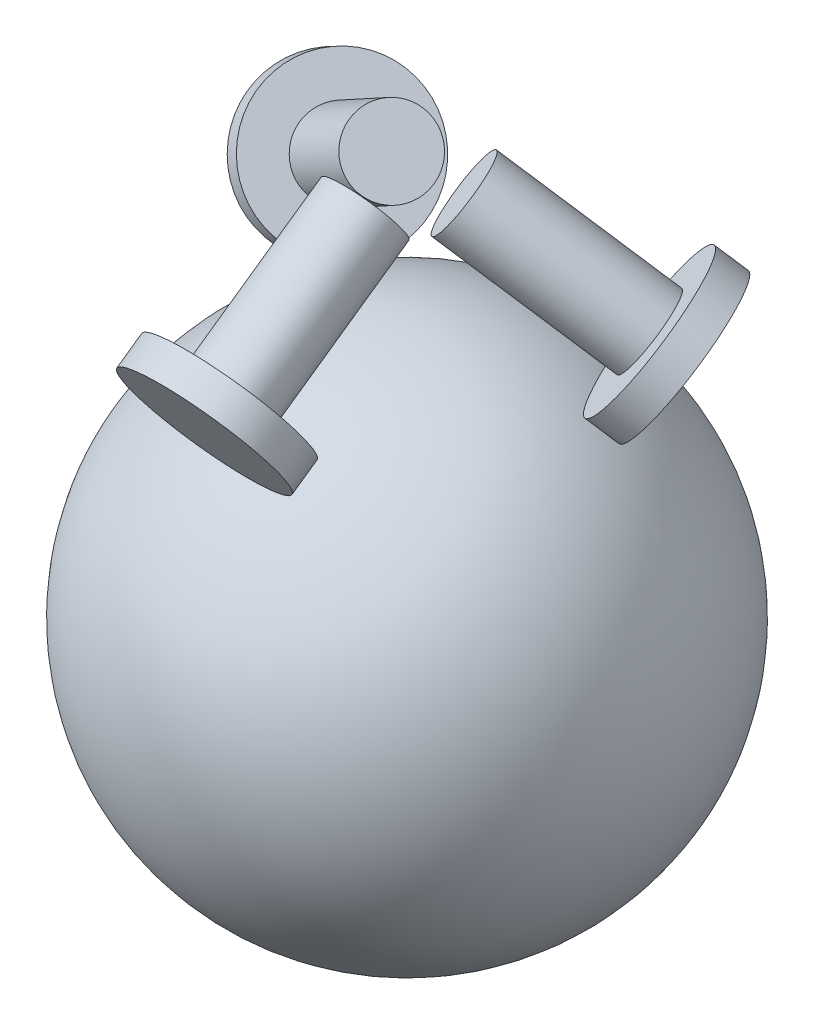
from build123d import *

# Parameters (mm, degrees)
SKETCH5_R                = 30
BOSS_EXTRUDE1_DEPTH      = 6
BOSS_EXTRUDE1_DEPTH_BACK = 6
BOSS_EXTRUDE2_START      = -6
SKETCH5_3_R              = 15
BOSS_EXTRUDE2_DEPTH      = 65
CIRPATTERN1_COUNT        = 3


with BuildPart() as part:
    # Sketch1 one side → Revolve2 (revolve)
    with BuildSketch(Plane(origin=(0, 0, 0), x_dir=(1, 0, 0), z_dir=(0, 1, 0))):
        with BuildLine():
            Line((100, 0), (-100, 0))
            ThreePointArc((-100, 0), (0, -100), (100, 0))
        make_face()
    revolve(axis=Axis((100, 0, 0), (-1, 0, 0)))


with BuildPart() as body_2:
    # Sketch5 → Boss-Extrude1 (new body, two sides)
    with BuildSketch(Plane(origin=(0, 0, 0), x_dir=(1, 0, 0), z_dir=(0, -0.573576436, 0.819152044))) as boss_extrude1_sk:
        with Locations((0, 130)):
            Circle(SKETCH5_R)
    extrude(amount=BOSS_EXTRUDE1_DEPTH)
    extrude(boss_extrude1_sk.sketch, amount=-BOSS_EXTRUDE1_DEPTH_BACK)

    # Sketch5_3 → Boss-Extrude2 (add)
    with BuildSketch(Plane(origin=(0, 0, 0), x_dir=(1, 0, 0), z_dir=(0, -0.573576436, 0.819152044)).offset(BOSS_EXTRUDE2_START)):
        with Locations((0, 130)):
            Circle(SKETCH5_3_R)
    extrude(amount=-BOSS_EXTRUDE2_DEPTH)


with BuildPart() as cirpattern1_1:
    # CirPattern1: pattern copy
    add(body_2.part.rotate(Axis((0, 0, 0), (0, 1, 0)), 1 * 360 / CIRPATTERN1_COUNT))


with BuildPart() as cirpattern1_2:
    # CirPattern1: pattern copy
    add(body_2.part.rotate(Axis((0, 0, 0), (0, 1, 0)), 2 * 360 / CIRPATTERN1_COUNT))


solid = Compound([part.part, body_2.part, cirpattern1_1.part, cirpattern1_2.part])
